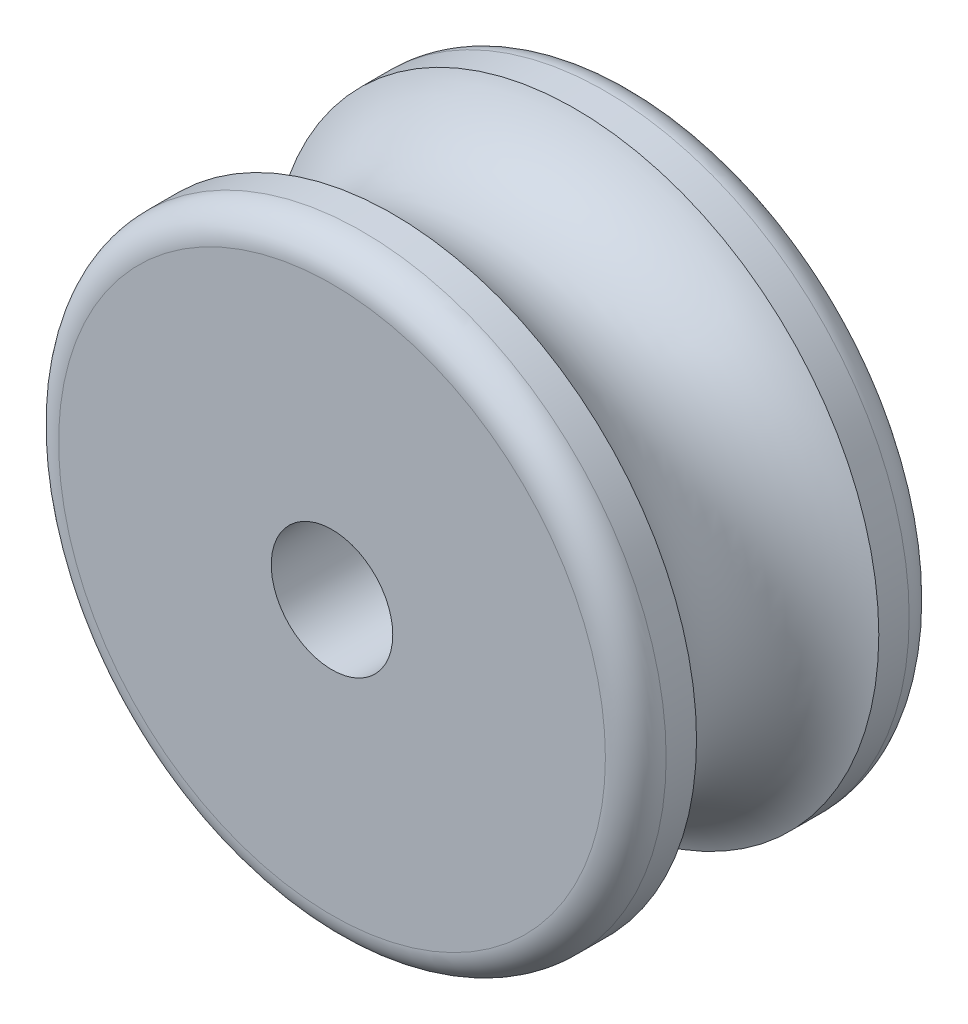
from build123d import *

# Parameters (mm, degrees)
SKETCH1_R           = 5
BOSS_EXTRUDE1_DEPTH = 5
FILLET1_R           = 0.5
SKETCH4_R           = 1
CUT_EXTRUDE1_DEPTH  = 5


with BuildPart() as part:
    # Sketch1 → Boss-Extrude1 (new body)
    with BuildSketch(Plane.XY):
        Circle(SKETCH1_R)
    extrude(amount=BOSS_EXTRUDE1_DEPTH)

    # Sketch2 → Cut-Revolve1 (revolve, cut)
    with BuildSketch(Plane(origin=(0, 0, 0), x_dir=(0, 0, -1), z_dir=(1, 0, 0))):
        with BuildLine():
            Line((-4, 5), (-1, 5))
            ThreePointArc((-1, 5), (-2.5, 4), (-4, 5))
        make_face()
    revolve(axis=Axis((0, 0, 5.25), (0, 0, -1)), mode=Mode.SUBTRACT)

    # Fillet1
    fillet1_edges = [part.edges().sort_by_distance(p)[0] for p in [
        (-5, 0, 0),
        (-5, 0, 5),
    ]]
    fillet(fillet1_edges, radius=FILLET1_R)

    # Sketch4 → Cut-Extrude1 (cut)
    with BuildSketch(Plane.XY.offset(5)):
        Circle(SKETCH4_R)
    extrude(amount=-CUT_EXTRUDE1_DEPTH, mode=Mode.SUBTRACT)


solid = part.part
